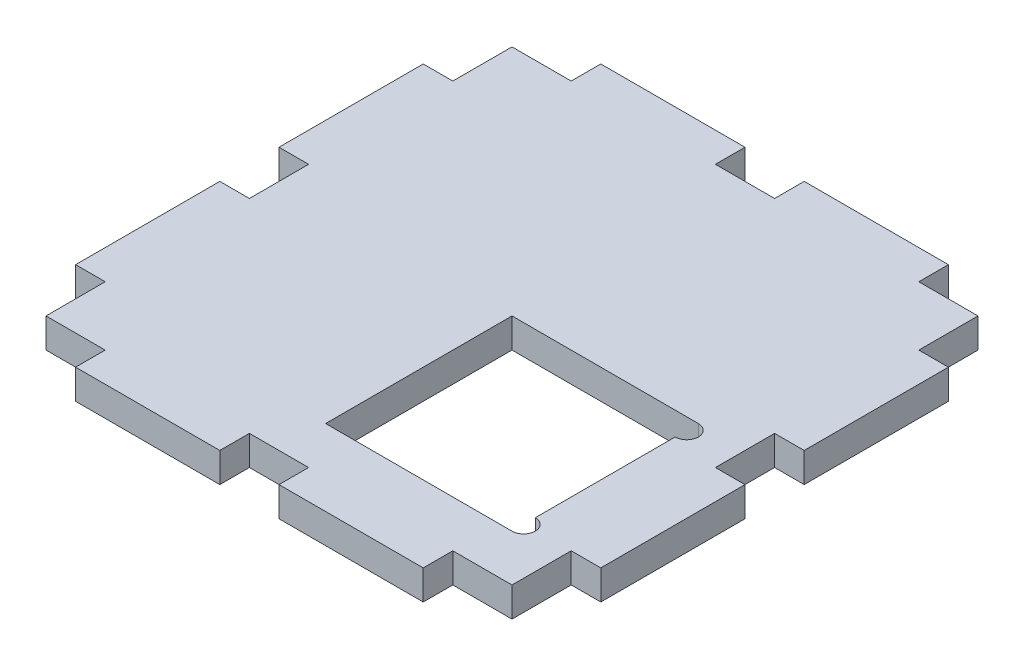
from build123d import *

# Parameters (mm, degrees)
SKETCH1_W           = 112.7
SKETCH1_H           = 112.7
BOSS_EXTRUDE1_DEPTH = 6.35
SKETCH2_W           = 12.7
SKETCH2_H           = 6.35
CUT_EXTRUDE2_DEPTH  = 7.35
CIRPATTERN1_COUNT   = 4
SKETCH5_W           = 6.35
SKETCH5_H           = 19.05
CUT_EXTRUDE3_DEPTH  = 7.35
SKETCH6_W           = 12.7
SKETCH6_H           = 6.35
CUT_EXTRUDE4_DEPTH  = 7.35
CIRPATTERN2_COUNT   = 4
CIRPATTERN3_COUNT   = 4
SKETCH7_W           = 40
SKETCH7_H           = 40
CUT_EXTRUDE5_DEPTH  = 7.35
CUT_EXTRUDE6_START  = -7.35
CUT_EXTRUDE6_DEPTH  = 8.35


with BuildPart() as part:
    # Sketch1 → Boss-Extrude1 (new body)
    with BuildSketch(Plane(origin=(0, 0, 0), x_dir=(1, 0, 0), z_dir=(0, 1, 0))):
        Rectangle(SKETCH1_W, SKETCH1_H)
    extrude(amount=BOSS_EXTRUDE1_DEPTH)

    # Sketch2 → Cut-Extrude2 (cut, through all)
    with BuildSketch(Plane(origin=(0, 6.35, 0), x_dir=(1, 0, 0), z_dir=(0, 1, 0))):
        with Locations((0, 53.175)):
            Rectangle(SKETCH2_W, SKETCH2_H)
    cut_extrude2 = extrude(amount=-CUT_EXTRUDE2_DEPTH, mode=Mode.SUBTRACT)

    # CirPattern1: Cut-Extrude2 ×4 about axis
    cirpattern1_axis = Axis((0, 0, 0), (0, 1, 0))
    for i in range(1, CIRPATTERN1_COUNT):
        add(cut_extrude2.rotate(cirpattern1_axis, i * 360 / CIRPATTERN1_COUNT), mode=Mode.SUBTRACT)

    # Sketch5 → Cut-Extrude3 (cut, through all)
    with BuildSketch(Plane(origin=(0, 6.35, 0), x_dir=(1, 0, 0), z_dir=(0, 1, 0))):
        with Locations((53.175, -46.825)):
            Rectangle(SKETCH5_W, SKETCH5_H)
    cut_extrude3 = extrude(amount=-CUT_EXTRUDE3_DEPTH, mode=Mode.SUBTRACT)

    # Sketch6 → Cut-Extrude4 (cut, through all)
    with BuildSketch(Plane(origin=(0, 6.35, 0), x_dir=(1, 0, 0), z_dir=(0, 1, 0))):
        with Locations((43.65, -53.175)):
            Rectangle(SKETCH6_W, SKETCH6_H)
    cut_extrude4 = extrude(amount=-CUT_EXTRUDE4_DEPTH, mode=Mode.SUBTRACT)

    # CirPattern2: Cut-Extrude3 ×4 about axis
    cirpattern2_axis = Axis((0, 0, 0), (0, 1, 0))
    for i in range(1, CIRPATTERN2_COUNT):
        add(cut_extrude3.rotate(cirpattern2_axis, i * 360 / CIRPATTERN2_COUNT), mode=Mode.SUBTRACT)

    # CirPattern3: Cut-Extrude4 ×4 about axis
    cirpattern3_axis = Axis((0, 0, 0), (0, 1, 0))
    for i in range(1, CIRPATTERN3_COUNT):
        add(cut_extrude4.rotate(cirpattern3_axis, i * 360 / CIRPATTERN3_COUNT), mode=Mode.SUBTRACT)

    # Sketch7 → Cut-Extrude5 (cut, through all)
    with BuildSketch(Plane(origin=(0, 6.35, 0), x_dir=(1, 0, 0), z_dir=(0, 1, 0))):
        with Locations((20, -20)):
            Rectangle(SKETCH7_W, SKETCH7_H)
    extrude(amount=-CUT_EXTRUDE5_DEPTH, mode=Mode.SUBTRACT)

    # Sketch8 → Cut-Extrude6 (cut)
    with BuildSketch(Plane(origin=(0, 6.35, 0), x_dir=(1, 0, 0), z_dir=(0, 1, 0)).offset(CUT_EXTRUDE6_START)):
        with BuildLine():
            Line((40, -35), (40, -40))
            ThreePointArc((40, -40), (42.5, -37.5), (40, -35))
        make_face()
    cut_extrude6 = extrude(amount=CUT_EXTRUDE6_DEPTH, mode=Mode.SUBTRACT)

    # Mirror1: Cut-Extrude6 across plane
    add(cut_extrude6.mirror(Plane(origin=(0, 3.175, 20), x_dir=(1, 0, 0), z_dir=(0, 0, 1))), mode=Mode.SUBTRACT)


solid = part.part
